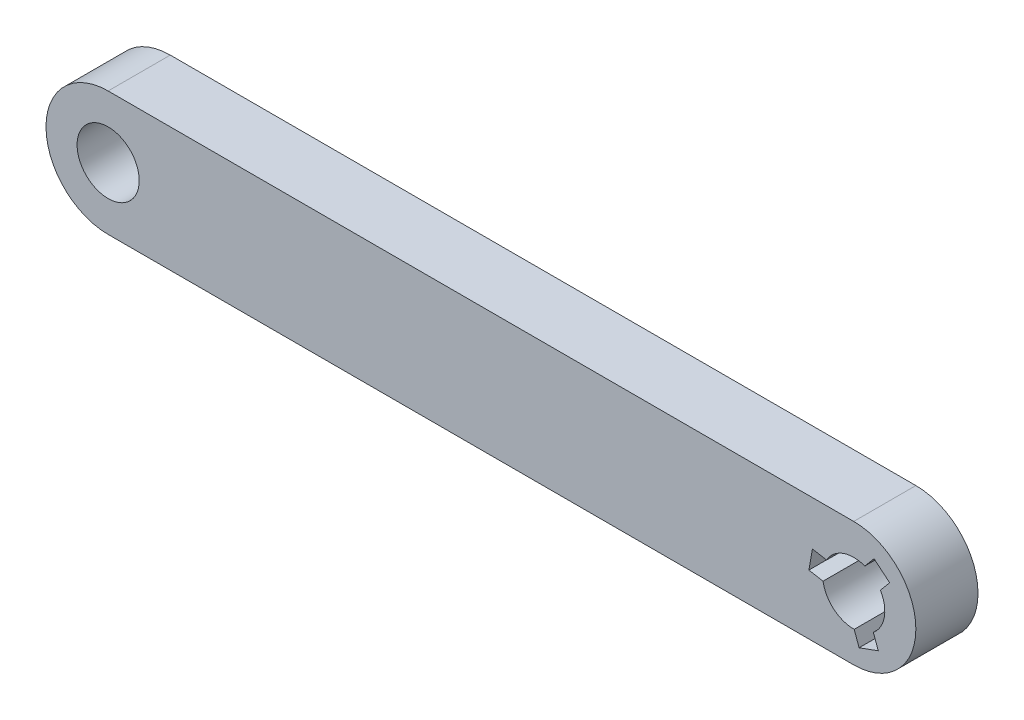
from build123d import *

# Parameters (mm, degrees)
SKETCH1_R        = 3.175
EXTRUSION1_DEPTH = 6.35


with BuildPart() as part:
    # Sketch1 → Extrusion1 (new body)
    with BuildSketch(Plane.XY):
        with BuildLine():
            Line((-76.2, -6.35), (0, -6.35))
            ThreePointArc((0, -6.35), (6.35, 0), (0, 6.35))
            Line((0, 6.35), (-76.2, 6.35))
            ThreePointArc((-76.2, 6.35), (-82.55, 0), (-76.2, -6.35))
        make_face()
        with Locations((-76.2, 0)):
            Circle(SKETCH1_R, mode=Mode.SUBTRACT)
        with BuildLine():
            ThreePointArc((2.004434618, -2.462288948), (3.126764616, -0.551332964), (2.725704838, 1.62823774))
            Line((2.725704838, 1.62823774), (3.671276413, 2.755126062))
            Line((3.671276413, 2.755126062), (2.87351773, 3.424525079))
            Line((2.87351773, 3.424525079), (2.075759047, 4.093924095))
            Line((2.075759047, 4.093924095), (1.130187472, 2.967035773))
            ThreePointArc((1.130187472, 2.967035773), (-1.085913955, 2.983524071), (-2.772947665, 1.546410763))
            Line((-2.772947665, 1.546410763), (-4.221647367, 1.801855607))
            Line((-4.221647367, 1.801855607), (-4.402484579, 0.776276813))
            Line((-4.402484579, 0.776276813), (-4.583321791, -0.249301981))
            Line((-4.583321791, -0.249301981), (-3.134622089, -0.504746825))
            ThreePointArc((-3.134622089, -0.504746825), (-2.040850661, -2.432191107), (0.047242827, -3.174648503))
            Line((0.047242827, -3.174648503), (0.550370953, -4.556981669))
            Line((0.550370953, -4.556981669), (1.528966849, -4.200801892))
            Line((1.528966849, -4.200801892), (2.507562744, -3.844622115))
            Line((2.507562744, -3.844622115), (2.004434618, -2.462288948))
        make_face(mode=Mode.SUBTRACT)
    extrude(amount=EXTRUSION1_DEPTH)


solid = part.part
